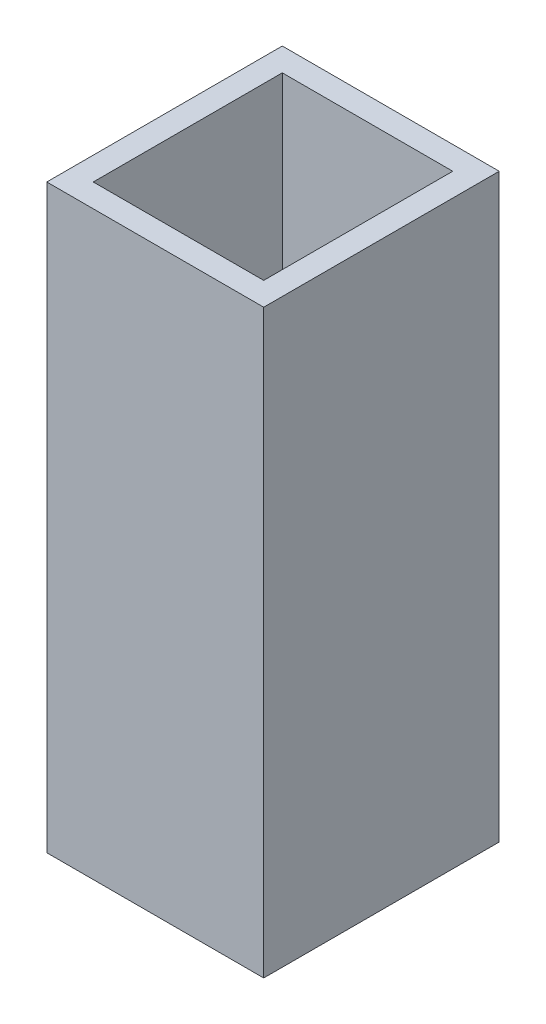
from build123d import *

# Parameters (mm, degrees)
SKETCH1_W                  = 18.67
SKETCH1_H                  = 20.27
EXTRUDE1_DEPTH             = 50
SHELL1_T                   = -2
SKETCH5_W                  = 1
SKETCH5_H                  = 1
EXTRUDE3_DEPTH             = 2
LPATTERN1_COUNT            = 8
LPATTERN1_PITCH            = 2.1429
LPATTERN2_COUNT            = 9
LPATTERN2_PITCH            = 2.125
LPATTERN2_COPY_1_SKETCH_W  = 1
LPATTERN2_COPY_1_SKETCH_H  = 1
LPATTERN2_COPY_1_DEPTH     = 2
LPATTERN2_COPY_2_SKETCH_W  = 1
LPATTERN2_COPY_2_SKETCH_H  = 1
LPATTERN2_COPY_2_DEPTH     = 2
LPATTERN2_COPY_3_SKETCH_W  = 1
LPATTERN2_COPY_3_SKETCH_H  = 1
LPATTERN2_COPY_3_DEPTH     = 2
LPATTERN2_COPY_4_SKETCH_W  = 1
LPATTERN2_COPY_4_SKETCH_H  = 1
LPATTERN2_COPY_4_DEPTH     = 2
LPATTERN2_COPY_5_SKETCH_W  = 1
LPATTERN2_COPY_5_SKETCH_H  = 1
LPATTERN2_COPY_5_DEPTH     = 2
LPATTERN2_COPY_6_SKETCH_W  = 1
LPATTERN2_COPY_6_SKETCH_H  = 1
LPATTERN2_COPY_6_DEPTH     = 2
LPATTERN2_COPY_7_SKETCH_W  = 1
LPATTERN2_COPY_7_SKETCH_H  = 1
LPATTERN2_COPY_7_DEPTH     = 2
LPATTERN2_COPY_8_SKETCH_W  = 1
LPATTERN2_COPY_8_SKETCH_H  = 1
LPATTERN2_COPY_8_DEPTH     = 2
LPATTERN2_COPY_9_SKETCH_W  = 1
LPATTERN2_COPY_9_SKETCH_H  = 1
LPATTERN2_COPY_9_DEPTH     = 2
LPATTERN2_COPY_10_SKETCH_W = 1
LPATTERN2_COPY_10_SKETCH_H = 1
LPATTERN2_COPY_10_DEPTH    = 2
LPATTERN2_COPY_11_SKETCH_W = 1
LPATTERN2_COPY_11_SKETCH_H = 1
LPATTERN2_COPY_11_DEPTH    = 2
LPATTERN2_COPY_12_SKETCH_W = 1
LPATTERN2_COPY_12_SKETCH_H = 1
LPATTERN2_COPY_12_DEPTH    = 2
LPATTERN2_COPY_13_SKETCH_W = 1
LPATTERN2_COPY_13_SKETCH_H = 1
LPATTERN2_COPY_13_DEPTH    = 2
LPATTERN2_COPY_14_SKETCH_W = 1
LPATTERN2_COPY_14_SKETCH_H = 1
LPATTERN2_COPY_14_DEPTH    = 2
LPATTERN2_COPY_15_SKETCH_W = 1
LPATTERN2_COPY_15_SKETCH_H = 1
LPATTERN2_COPY_15_DEPTH    = 2
LPATTERN2_COPY_16_SKETCH_W = 1
LPATTERN2_COPY_16_SKETCH_H = 1
LPATTERN2_COPY_16_DEPTH    = 2
LPATTERN2_COPY_17_SKETCH_W = 1
LPATTERN2_COPY_17_SKETCH_H = 1
LPATTERN2_COPY_17_DEPTH    = 2
LPATTERN2_COPY_18_SKETCH_W = 1
LPATTERN2_COPY_18_SKETCH_H = 1
LPATTERN2_COPY_18_DEPTH    = 2
LPATTERN2_COPY_19_SKETCH_W = 1
LPATTERN2_COPY_19_SKETCH_H = 1
LPATTERN2_COPY_19_DEPTH    = 2
LPATTERN2_COPY_20_SKETCH_W = 1
LPATTERN2_COPY_20_SKETCH_H = 1
LPATTERN2_COPY_20_DEPTH    = 2
LPATTERN2_COPY_21_SKETCH_W = 1
LPATTERN2_COPY_21_SKETCH_H = 1
LPATTERN2_COPY_21_DEPTH    = 2
LPATTERN2_COPY_22_SKETCH_W = 1
LPATTERN2_COPY_22_SKETCH_H = 1
LPATTERN2_COPY_22_DEPTH    = 2
LPATTERN2_COPY_23_SKETCH_W = 1
LPATTERN2_COPY_23_SKETCH_H = 1
LPATTERN2_COPY_23_DEPTH    = 2
LPATTERN2_COPY_24_SKETCH_W = 1
LPATTERN2_COPY_24_SKETCH_H = 1
LPATTERN2_COPY_24_DEPTH    = 2
LPATTERN2_COPY_25_SKETCH_W = 1
LPATTERN2_COPY_25_SKETCH_H = 1
LPATTERN2_COPY_25_DEPTH    = 2
LPATTERN2_COPY_26_SKETCH_W = 1
LPATTERN2_COPY_26_SKETCH_H = 1
LPATTERN2_COPY_26_DEPTH    = 2
LPATTERN2_COPY_27_SKETCH_W = 1
LPATTERN2_COPY_27_SKETCH_H = 1
LPATTERN2_COPY_27_DEPTH    = 2
LPATTERN2_COPY_28_SKETCH_W = 1
LPATTERN2_COPY_28_SKETCH_H = 1
LPATTERN2_COPY_28_DEPTH    = 2
LPATTERN2_COPY_29_SKETCH_W = 1
LPATTERN2_COPY_29_SKETCH_H = 1
LPATTERN2_COPY_29_DEPTH    = 2
LPATTERN2_COPY_30_SKETCH_W = 1
LPATTERN2_COPY_30_SKETCH_H = 1
LPATTERN2_COPY_30_DEPTH    = 2
LPATTERN2_COPY_31_SKETCH_W = 1
LPATTERN2_COPY_31_SKETCH_H = 1
LPATTERN2_COPY_31_DEPTH    = 2
LPATTERN2_COPY_32_SKETCH_W = 1
LPATTERN2_COPY_32_SKETCH_H = 1
LPATTERN2_COPY_32_DEPTH    = 2
LPATTERN2_COPY_33_SKETCH_W = 1
LPATTERN2_COPY_33_SKETCH_H = 1
LPATTERN2_COPY_33_DEPTH    = 2
LPATTERN2_COPY_34_SKETCH_W = 1
LPATTERN2_COPY_34_SKETCH_H = 1
LPATTERN2_COPY_34_DEPTH    = 2
LPATTERN2_COPY_35_SKETCH_W = 1
LPATTERN2_COPY_35_SKETCH_H = 1
LPATTERN2_COPY_35_DEPTH    = 2
LPATTERN2_COPY_36_SKETCH_W = 1
LPATTERN2_COPY_36_SKETCH_H = 1
LPATTERN2_COPY_36_DEPTH    = 2
LPATTERN2_COPY_37_SKETCH_W = 1
LPATTERN2_COPY_37_SKETCH_H = 1
LPATTERN2_COPY_37_DEPTH    = 2
LPATTERN2_COPY_38_SKETCH_W = 1
LPATTERN2_COPY_38_SKETCH_H = 1
LPATTERN2_COPY_38_DEPTH    = 2
LPATTERN2_COPY_39_SKETCH_W = 1
LPATTERN2_COPY_39_SKETCH_H = 1
LPATTERN2_COPY_39_DEPTH    = 2
LPATTERN2_COPY_40_SKETCH_W = 1
LPATTERN2_COPY_40_SKETCH_H = 1
LPATTERN2_COPY_40_DEPTH    = 2
LPATTERN2_COPY_41_SKETCH_W = 1
LPATTERN2_COPY_41_SKETCH_H = 1
LPATTERN2_COPY_41_DEPTH    = 2
LPATTERN2_COPY_42_SKETCH_W = 1
LPATTERN2_COPY_42_SKETCH_H = 1
LPATTERN2_COPY_42_DEPTH    = 2
LPATTERN2_COPY_43_SKETCH_W = 1
LPATTERN2_COPY_43_SKETCH_H = 1
LPATTERN2_COPY_43_DEPTH    = 2
LPATTERN2_COPY_44_SKETCH_W = 1
LPATTERN2_COPY_44_SKETCH_H = 1
LPATTERN2_COPY_44_DEPTH    = 2
LPATTERN2_COPY_45_SKETCH_W = 1
LPATTERN2_COPY_45_SKETCH_H = 1
LPATTERN2_COPY_45_DEPTH    = 2
LPATTERN2_COPY_46_SKETCH_W = 1
LPATTERN2_COPY_46_SKETCH_H = 1
LPATTERN2_COPY_46_DEPTH    = 2
LPATTERN2_COPY_47_SKETCH_W = 1
LPATTERN2_COPY_47_SKETCH_H = 1
LPATTERN2_COPY_47_DEPTH    = 2
LPATTERN2_COPY_48_SKETCH_W = 1
LPATTERN2_COPY_48_SKETCH_H = 1
LPATTERN2_COPY_48_DEPTH    = 2
LPATTERN2_COPY_49_SKETCH_W = 1
LPATTERN2_COPY_49_SKETCH_H = 1
LPATTERN2_COPY_49_DEPTH    = 2
LPATTERN2_COPY_50_SKETCH_W = 1
LPATTERN2_COPY_50_SKETCH_H = 1
LPATTERN2_COPY_50_DEPTH    = 2
LPATTERN2_COPY_51_SKETCH_W = 1
LPATTERN2_COPY_51_SKETCH_H = 1
LPATTERN2_COPY_51_DEPTH    = 2
LPATTERN2_COPY_52_SKETCH_W = 1
LPATTERN2_COPY_52_SKETCH_H = 1
LPATTERN2_COPY_52_DEPTH    = 2
LPATTERN2_COPY_53_SKETCH_W = 1
LPATTERN2_COPY_53_SKETCH_H = 1
LPATTERN2_COPY_53_DEPTH    = 2
LPATTERN2_COPY_54_SKETCH_W = 1
LPATTERN2_COPY_54_SKETCH_H = 1
LPATTERN2_COPY_54_DEPTH    = 2
LPATTERN2_COPY_55_SKETCH_W = 1
LPATTERN2_COPY_55_SKETCH_H = 1
LPATTERN2_COPY_55_DEPTH    = 2
LPATTERN2_COPY_56_SKETCH_W = 1
LPATTERN2_COPY_56_SKETCH_H = 1
LPATTERN2_COPY_56_DEPTH    = 2
SKETCH6_W                  = 16.67
SKETCH6_H                  = 18.27
CUT_EXTRUDE1_DEPTH         = 1.5


with BuildPart() as part:
    # Sketch1 → Extrude1 (new body)
    with BuildSketch(Plane(origin=(0, 0, 0), x_dir=(1, 0, 0), z_dir=(0, 1, 0))):
        Rectangle(SKETCH1_W, SKETCH1_H)
    extrude(amount=EXTRUDE1_DEPTH)

    # Shell1
    shell1_openings = [part.faces().sort_by_distance(p)[0] for p in [
        (0, 50, 0),
    ]]
    offset(amount=SHELL1_T, openings=shell1_openings, kind=Kind.INTERSECTION)

    # Sketch5 → Extrude3 (cut)
    with BuildSketch(Plane.XZ):
        with Locations((-7.5, -8.5)):
            Rectangle(SKETCH5_W, SKETCH5_H)
    extrude3 = extrude(amount=-EXTRUDE3_DEPTH, mode=Mode.SUBTRACT)

    # LPattern1: Extrude3 ×8
    with Locations(*[(i * LPATTERN1_PITCH, 0, 0) for i in range(1, LPATTERN1_COUNT)]):
        add(extrude3, mode=Mode.SUBTRACT)

    # LPattern2: Extrude3 ×9
    with Locations(*[(0, 0, i * LPATTERN2_PITCH) for i in range(1, LPATTERN2_COUNT)]):
        add(extrude3, mode=Mode.SUBTRACT)

    # LPattern2 copy 1 sketch → LPattern2 copy 1 (cut)
    with BuildSketch(Plane(origin=(2.1429, 0, 2.125), x_dir=(1, 0, 0), z_dir=(0, -1, 0))):
        with Locations((-7.5, -8.5)):
            Rectangle(LPATTERN2_COPY_1_SKETCH_W, LPATTERN2_COPY_1_SKETCH_H)
    extrude(amount=-LPATTERN2_COPY_1_DEPTH, mode=Mode.SUBTRACT)

    # LPattern2 copy 2 sketch → LPattern2 copy 2 (cut)
    with BuildSketch(Plane(origin=(2.1429, 0, 4.25), x_dir=(1, 0, 0), z_dir=(0, -1, 0))):
        with Locations((-7.5, -8.5)):
            Rectangle(LPATTERN2_COPY_2_SKETCH_W, LPATTERN2_COPY_2_SKETCH_H)
    extrude(amount=-LPATTERN2_COPY_2_DEPTH, mode=Mode.SUBTRACT)

    # LPattern2 copy 3 sketch → LPattern2 copy 3 (cut)
    with BuildSketch(Plane(origin=(2.1429, 0, 6.375), x_dir=(1, 0, 0), z_dir=(0, -1, 0))):
        with Locations((-7.5, -8.5)):
            Rectangle(LPATTERN2_COPY_3_SKETCH_W, LPATTERN2_COPY_3_SKETCH_H)
    extrude(amount=-LPATTERN2_COPY_3_DEPTH, mode=Mode.SUBTRACT)

    # LPattern2 copy 4 sketch → LPattern2 copy 4 (cut)
    with BuildSketch(Plane(origin=(2.1429, 0, 8.5), x_dir=(1, 0, 0), z_dir=(0, -1, 0))):
        with Locations((-7.5, -8.5)):
            Rectangle(LPATTERN2_COPY_4_SKETCH_W, LPATTERN2_COPY_4_SKETCH_H)
    extrude(amount=-LPATTERN2_COPY_4_DEPTH, mode=Mode.SUBTRACT)

    # LPattern2 copy 5 sketch → LPattern2 copy 5 (cut)
    with BuildSketch(Plane(origin=(2.1429, 0, 10.625), x_dir=(1, 0, 0), z_dir=(0, -1, 0))):
        with Locations((-7.5, -8.5)):
            Rectangle(LPATTERN2_COPY_5_SKETCH_W, LPATTERN2_COPY_5_SKETCH_H)
    extrude(amount=-LPATTERN2_COPY_5_DEPTH, mode=Mode.SUBTRACT)

    # LPattern2 copy 6 sketch → LPattern2 copy 6 (cut)
    with BuildSketch(Plane(origin=(2.1429, 0, 12.75), x_dir=(1, 0, 0), z_dir=(0, -1, 0))):
        with Locations((-7.5, -8.5)):
            Rectangle(LPATTERN2_COPY_6_SKETCH_W, LPATTERN2_COPY_6_SKETCH_H)
    extrude(amount=-LPATTERN2_COPY_6_DEPTH, mode=Mode.SUBTRACT)

    # LPattern2 copy 7 sketch → LPattern2 copy 7 (cut)
    with BuildSketch(Plane(origin=(2.1429, 0, 14.875), x_dir=(1, 0, 0), z_dir=(0, -1, 0))):
        with Locations((-7.5, -8.5)):
            Rectangle(LPATTERN2_COPY_7_SKETCH_W, LPATTERN2_COPY_7_SKETCH_H)
    extrude(amount=-LPATTERN2_COPY_7_DEPTH, mode=Mode.SUBTRACT)

    # LPattern2 copy 8 sketch → LPattern2 copy 8 (cut)
    with BuildSketch(Plane(origin=(2.1429, 0, 17), x_dir=(1, 0, 0), z_dir=(0, -1, 0))):
        with Locations((-7.5, -8.5)):
            Rectangle(LPATTERN2_COPY_8_SKETCH_W, LPATTERN2_COPY_8_SKETCH_H)
    extrude(amount=-LPATTERN2_COPY_8_DEPTH, mode=Mode.SUBTRACT)

    # LPattern2 copy 9 sketch → LPattern2 copy 9 (cut)
    with BuildSketch(Plane(origin=(4.2858, 0, 2.125), x_dir=(1, 0, 0), z_dir=(0, -1, 0))):
        with Locations((-7.5, -8.5)):
            Rectangle(LPATTERN2_COPY_9_SKETCH_W, LPATTERN2_COPY_9_SKETCH_H)
    extrude(amount=-LPATTERN2_COPY_9_DEPTH, mode=Mode.SUBTRACT)

    # LPattern2 copy 10 sketch → LPattern2 copy 10 (cut)
    with BuildSketch(Plane(origin=(4.2858, 0, 4.25), x_dir=(1, 0, 0), z_dir=(0, -1, 0))):
        with Locations((-7.5, -8.5)):
            Rectangle(LPATTERN2_COPY_10_SKETCH_W, LPATTERN2_COPY_10_SKETCH_H)
    extrude(amount=-LPATTERN2_COPY_10_DEPTH, mode=Mode.SUBTRACT)

    # LPattern2 copy 11 sketch → LPattern2 copy 11 (cut)
    with BuildSketch(Plane(origin=(4.2858, 0, 6.375), x_dir=(1, 0, 0), z_dir=(0, -1, 0))):
        with Locations((-7.5, -8.5)):
            Rectangle(LPATTERN2_COPY_11_SKETCH_W, LPATTERN2_COPY_11_SKETCH_H)
    extrude(amount=-LPATTERN2_COPY_11_DEPTH, mode=Mode.SUBTRACT)

    # LPattern2 copy 12 sketch → LPattern2 copy 12 (cut)
    with BuildSketch(Plane(origin=(4.2858, 0, 8.5), x_dir=(1, 0, 0), z_dir=(0, -1, 0))):
        with Locations((-7.5, -8.5)):
            Rectangle(LPATTERN2_COPY_12_SKETCH_W, LPATTERN2_COPY_12_SKETCH_H)
    extrude(amount=-LPATTERN2_COPY_12_DEPTH, mode=Mode.SUBTRACT)

    # LPattern2 copy 13 sketch → LPattern2 copy 13 (cut)
    with BuildSketch(Plane(origin=(4.2858, 0, 10.625), x_dir=(1, 0, 0), z_dir=(0, -1, 0))):
        with Locations((-7.5, -8.5)):
            Rectangle(LPATTERN2_COPY_13_SKETCH_W, LPATTERN2_COPY_13_SKETCH_H)
    extrude(amount=-LPATTERN2_COPY_13_DEPTH, mode=Mode.SUBTRACT)

    # LPattern2 copy 14 sketch → LPattern2 copy 14 (cut)
    with BuildSketch(Plane(origin=(4.2858, 0, 12.75), x_dir=(1, 0, 0), z_dir=(0, -1, 0))):
        with Locations((-7.5, -8.5)):
            Rectangle(LPATTERN2_COPY_14_SKETCH_W, LPATTERN2_COPY_14_SKETCH_H)
    extrude(amount=-LPATTERN2_COPY_14_DEPTH, mode=Mode.SUBTRACT)

    # LPattern2 copy 15 sketch → LPattern2 copy 15 (cut)
    with BuildSketch(Plane(origin=(4.2858, 0, 14.875), x_dir=(1, 0, 0), z_dir=(0, -1, 0))):
        with Locations((-7.5, -8.5)):
            Rectangle(LPATTERN2_COPY_15_SKETCH_W, LPATTERN2_COPY_15_SKETCH_H)
    extrude(amount=-LPATTERN2_COPY_15_DEPTH, mode=Mode.SUBTRACT)

    # LPattern2 copy 16 sketch → LPattern2 copy 16 (cut)
    with BuildSketch(Plane(origin=(4.2858, 0, 17), x_dir=(1, 0, 0), z_dir=(0, -1, 0))):
        with Locations((-7.5, -8.5)):
            Rectangle(LPATTERN2_COPY_16_SKETCH_W, LPATTERN2_COPY_16_SKETCH_H)
    extrude(amount=-LPATTERN2_COPY_16_DEPTH, mode=Mode.SUBTRACT)

    # LPattern2 copy 17 sketch → LPattern2 copy 17 (cut)
    with BuildSketch(Plane(origin=(6.4287, 0, 2.125), x_dir=(1, 0, 0), z_dir=(0, -1, 0))):
        with Locations((-7.5, -8.5)):
            Rectangle(LPATTERN2_COPY_17_SKETCH_W, LPATTERN2_COPY_17_SKETCH_H)
    extrude(amount=-LPATTERN2_COPY_17_DEPTH, mode=Mode.SUBTRACT)

    # LPattern2 copy 18 sketch → LPattern2 copy 18 (cut)
    with BuildSketch(Plane(origin=(6.4287, 0, 4.25), x_dir=(1, 0, 0), z_dir=(0, -1, 0))):
        with Locations((-7.5, -8.5)):
            Rectangle(LPATTERN2_COPY_18_SKETCH_W, LPATTERN2_COPY_18_SKETCH_H)
    extrude(amount=-LPATTERN2_COPY_18_DEPTH, mode=Mode.SUBTRACT)

    # LPattern2 copy 19 sketch → LPattern2 copy 19 (cut)
    with BuildSketch(Plane(origin=(6.4287, 0, 6.375), x_dir=(1, 0, 0), z_dir=(0, -1, 0))):
        with Locations((-7.5, -8.5)):
            Rectangle(LPATTERN2_COPY_19_SKETCH_W, LPATTERN2_COPY_19_SKETCH_H)
    extrude(amount=-LPATTERN2_COPY_19_DEPTH, mode=Mode.SUBTRACT)

    # LPattern2 copy 20 sketch → LPattern2 copy 20 (cut)
    with BuildSketch(Plane(origin=(6.4287, 0, 8.5), x_dir=(1, 0, 0), z_dir=(0, -1, 0))):
        with Locations((-7.5, -8.5)):
            Rectangle(LPATTERN2_COPY_20_SKETCH_W, LPATTERN2_COPY_20_SKETCH_H)
    extrude(amount=-LPATTERN2_COPY_20_DEPTH, mode=Mode.SUBTRACT)

    # LPattern2 copy 21 sketch → LPattern2 copy 21 (cut)
    with BuildSketch(Plane(origin=(6.4287, 0, 10.625), x_dir=(1, 0, 0), z_dir=(0, -1, 0))):
        with Locations((-7.5, -8.5)):
            Rectangle(LPATTERN2_COPY_21_SKETCH_W, LPATTERN2_COPY_21_SKETCH_H)
    extrude(amount=-LPATTERN2_COPY_21_DEPTH, mode=Mode.SUBTRACT)

    # LPattern2 copy 22 sketch → LPattern2 copy 22 (cut)
    with BuildSketch(Plane(origin=(6.4287, 0, 12.75), x_dir=(1, 0, 0), z_dir=(0, -1, 0))):
        with Locations((-7.5, -8.5)):
            Rectangle(LPATTERN2_COPY_22_SKETCH_W, LPATTERN2_COPY_22_SKETCH_H)
    extrude(amount=-LPATTERN2_COPY_22_DEPTH, mode=Mode.SUBTRACT)

    # LPattern2 copy 23 sketch → LPattern2 copy 23 (cut)
    with BuildSketch(Plane(origin=(6.4287, 0, 14.875), x_dir=(1, 0, 0), z_dir=(0, -1, 0))):
        with Locations((-7.5, -8.5)):
            Rectangle(LPATTERN2_COPY_23_SKETCH_W, LPATTERN2_COPY_23_SKETCH_H)
    extrude(amount=-LPATTERN2_COPY_23_DEPTH, mode=Mode.SUBTRACT)

    # LPattern2 copy 24 sketch → LPattern2 copy 24 (cut)
    with BuildSketch(Plane(origin=(6.4287, 0, 17), x_dir=(1, 0, 0), z_dir=(0, -1, 0))):
        with Locations((-7.5, -8.5)):
            Rectangle(LPATTERN2_COPY_24_SKETCH_W, LPATTERN2_COPY_24_SKETCH_H)
    extrude(amount=-LPATTERN2_COPY_24_DEPTH, mode=Mode.SUBTRACT)

    # LPattern2 copy 25 sketch → LPattern2 copy 25 (cut)
    with BuildSketch(Plane(origin=(8.5716, 0, 2.125), x_dir=(1, 0, 0), z_dir=(0, -1, 0))):
        with Locations((-7.5, -8.5)):
            Rectangle(LPATTERN2_COPY_25_SKETCH_W, LPATTERN2_COPY_25_SKETCH_H)
    extrude(amount=-LPATTERN2_COPY_25_DEPTH, mode=Mode.SUBTRACT)

    # LPattern2 copy 26 sketch → LPattern2 copy 26 (cut)
    with BuildSketch(Plane(origin=(8.5716, 0, 4.25), x_dir=(1, 0, 0), z_dir=(0, -1, 0))):
        with Locations((-7.5, -8.5)):
            Rectangle(LPATTERN2_COPY_26_SKETCH_W, LPATTERN2_COPY_26_SKETCH_H)
    extrude(amount=-LPATTERN2_COPY_26_DEPTH, mode=Mode.SUBTRACT)

    # LPattern2 copy 27 sketch → LPattern2 copy 27 (cut)
    with BuildSketch(Plane(origin=(8.5716, 0, 6.375), x_dir=(1, 0, 0), z_dir=(0, -1, 0))):
        with Locations((-7.5, -8.5)):
            Rectangle(LPATTERN2_COPY_27_SKETCH_W, LPATTERN2_COPY_27_SKETCH_H)
    extrude(amount=-LPATTERN2_COPY_27_DEPTH, mode=Mode.SUBTRACT)

    # LPattern2 copy 28 sketch → LPattern2 copy 28 (cut)
    with BuildSketch(Plane(origin=(8.5716, 0, 8.5), x_dir=(1, 0, 0), z_dir=(0, -1, 0))):
        with Locations((-7.5, -8.5)):
            Rectangle(LPATTERN2_COPY_28_SKETCH_W, LPATTERN2_COPY_28_SKETCH_H)
    extrude(amount=-LPATTERN2_COPY_28_DEPTH, mode=Mode.SUBTRACT)

    # LPattern2 copy 29 sketch → LPattern2 copy 29 (cut)
    with BuildSketch(Plane(origin=(8.5716, 0, 10.625), x_dir=(1, 0, 0), z_dir=(0, -1, 0))):
        with Locations((-7.5, -8.5)):
            Rectangle(LPATTERN2_COPY_29_SKETCH_W, LPATTERN2_COPY_29_SKETCH_H)
    extrude(amount=-LPATTERN2_COPY_29_DEPTH, mode=Mode.SUBTRACT)

    # LPattern2 copy 30 sketch → LPattern2 copy 30 (cut)
    with BuildSketch(Plane(origin=(8.5716, 0, 12.75), x_dir=(1, 0, 0), z_dir=(0, -1, 0))):
        with Locations((-7.5, -8.5)):
            Rectangle(LPATTERN2_COPY_30_SKETCH_W, LPATTERN2_COPY_30_SKETCH_H)
    extrude(amount=-LPATTERN2_COPY_30_DEPTH, mode=Mode.SUBTRACT)

    # LPattern2 copy 31 sketch → LPattern2 copy 31 (cut)
    with BuildSketch(Plane(origin=(8.5716, 0, 14.875), x_dir=(1, 0, 0), z_dir=(0, -1, 0))):
        with Locations((-7.5, -8.5)):
            Rectangle(LPATTERN2_COPY_31_SKETCH_W, LPATTERN2_COPY_31_SKETCH_H)
    extrude(amount=-LPATTERN2_COPY_31_DEPTH, mode=Mode.SUBTRACT)

    # LPattern2 copy 32 sketch → LPattern2 copy 32 (cut)
    with BuildSketch(Plane(origin=(8.5716, 0, 17), x_dir=(1, 0, 0), z_dir=(0, -1, 0))):
        with Locations((-7.5, -8.5)):
            Rectangle(LPATTERN2_COPY_32_SKETCH_W, LPATTERN2_COPY_32_SKETCH_H)
    extrude(amount=-LPATTERN2_COPY_32_DEPTH, mode=Mode.SUBTRACT)

    # LPattern2 copy 33 sketch → LPattern2 copy 33 (cut)
    with BuildSketch(Plane(origin=(10.7145, 0, 2.125), x_dir=(1, 0, 0), z_dir=(0, -1, 0))):
        with Locations((-7.5, -8.5)):
            Rectangle(LPATTERN2_COPY_33_SKETCH_W, LPATTERN2_COPY_33_SKETCH_H)
    extrude(amount=-LPATTERN2_COPY_33_DEPTH, mode=Mode.SUBTRACT)

    # LPattern2 copy 34 sketch → LPattern2 copy 34 (cut)
    with BuildSketch(Plane(origin=(10.7145, 0, 4.25), x_dir=(1, 0, 0), z_dir=(0, -1, 0))):
        with Locations((-7.5, -8.5)):
            Rectangle(LPATTERN2_COPY_34_SKETCH_W, LPATTERN2_COPY_34_SKETCH_H)
    extrude(amount=-LPATTERN2_COPY_34_DEPTH, mode=Mode.SUBTRACT)

    # LPattern2 copy 35 sketch → LPattern2 copy 35 (cut)
    with BuildSketch(Plane(origin=(10.7145, 0, 6.375), x_dir=(1, 0, 0), z_dir=(0, -1, 0))):
        with Locations((-7.5, -8.5)):
            Rectangle(LPATTERN2_COPY_35_SKETCH_W, LPATTERN2_COPY_35_SKETCH_H)
    extrude(amount=-LPATTERN2_COPY_35_DEPTH, mode=Mode.SUBTRACT)

    # LPattern2 copy 36 sketch → LPattern2 copy 36 (cut)
    with BuildSketch(Plane(origin=(10.7145, 0, 8.5), x_dir=(1, 0, 0), z_dir=(0, -1, 0))):
        with Locations((-7.5, -8.5)):
            Rectangle(LPATTERN2_COPY_36_SKETCH_W, LPATTERN2_COPY_36_SKETCH_H)
    extrude(amount=-LPATTERN2_COPY_36_DEPTH, mode=Mode.SUBTRACT)

    # LPattern2 copy 37 sketch → LPattern2 copy 37 (cut)
    with BuildSketch(Plane(origin=(10.7145, 0, 10.625), x_dir=(1, 0, 0), z_dir=(0, -1, 0))):
        with Locations((-7.5, -8.5)):
            Rectangle(LPATTERN2_COPY_37_SKETCH_W, LPATTERN2_COPY_37_SKETCH_H)
    extrude(amount=-LPATTERN2_COPY_37_DEPTH, mode=Mode.SUBTRACT)

    # LPattern2 copy 38 sketch → LPattern2 copy 38 (cut)
    with BuildSketch(Plane(origin=(10.7145, 0, 12.75), x_dir=(1, 0, 0), z_dir=(0, -1, 0))):
        with Locations((-7.5, -8.5)):
            Rectangle(LPATTERN2_COPY_38_SKETCH_W, LPATTERN2_COPY_38_SKETCH_H)
    extrude(amount=-LPATTERN2_COPY_38_DEPTH, mode=Mode.SUBTRACT)

    # LPattern2 copy 39 sketch → LPattern2 copy 39 (cut)
    with BuildSketch(Plane(origin=(10.7145, 0, 14.875), x_dir=(1, 0, 0), z_dir=(0, -1, 0))):
        with Locations((-7.5, -8.5)):
            Rectangle(LPATTERN2_COPY_39_SKETCH_W, LPATTERN2_COPY_39_SKETCH_H)
    extrude(amount=-LPATTERN2_COPY_39_DEPTH, mode=Mode.SUBTRACT)

    # LPattern2 copy 40 sketch → LPattern2 copy 40 (cut)
    with BuildSketch(Plane(origin=(10.7145, 0, 17), x_dir=(1, 0, 0), z_dir=(0, -1, 0))):
        with Locations((-7.5, -8.5)):
            Rectangle(LPATTERN2_COPY_40_SKETCH_W, LPATTERN2_COPY_40_SKETCH_H)
    extrude(amount=-LPATTERN2_COPY_40_DEPTH, mode=Mode.SUBTRACT)

    # LPattern2 copy 41 sketch → LPattern2 copy 41 (cut)
    with BuildSketch(Plane(origin=(12.8574, 0, 2.125), x_dir=(1, 0, 0), z_dir=(0, -1, 0))):
        with Locations((-7.5, -8.5)):
            Rectangle(LPATTERN2_COPY_41_SKETCH_W, LPATTERN2_COPY_41_SKETCH_H)
    extrude(amount=-LPATTERN2_COPY_41_DEPTH, mode=Mode.SUBTRACT)

    # LPattern2 copy 42 sketch → LPattern2 copy 42 (cut)
    with BuildSketch(Plane(origin=(12.8574, 0, 4.25), x_dir=(1, 0, 0), z_dir=(0, -1, 0))):
        with Locations((-7.5, -8.5)):
            Rectangle(LPATTERN2_COPY_42_SKETCH_W, LPATTERN2_COPY_42_SKETCH_H)
    extrude(amount=-LPATTERN2_COPY_42_DEPTH, mode=Mode.SUBTRACT)

    # LPattern2 copy 43 sketch → LPattern2 copy 43 (cut)
    with BuildSketch(Plane(origin=(12.8574, 0, 6.375), x_dir=(1, 0, 0), z_dir=(0, -1, 0))):
        with Locations((-7.5, -8.5)):
            Rectangle(LPATTERN2_COPY_43_SKETCH_W, LPATTERN2_COPY_43_SKETCH_H)
    extrude(amount=-LPATTERN2_COPY_43_DEPTH, mode=Mode.SUBTRACT)

    # LPattern2 copy 44 sketch → LPattern2 copy 44 (cut)
    with BuildSketch(Plane(origin=(12.8574, 0, 8.5), x_dir=(1, 0, 0), z_dir=(0, -1, 0))):
        with Locations((-7.5, -8.5)):
            Rectangle(LPATTERN2_COPY_44_SKETCH_W, LPATTERN2_COPY_44_SKETCH_H)
    extrude(amount=-LPATTERN2_COPY_44_DEPTH, mode=Mode.SUBTRACT)

    # LPattern2 copy 45 sketch → LPattern2 copy 45 (cut)
    with BuildSketch(Plane(origin=(12.8574, 0, 10.625), x_dir=(1, 0, 0), z_dir=(0, -1, 0))):
        with Locations((-7.5, -8.5)):
            Rectangle(LPATTERN2_COPY_45_SKETCH_W, LPATTERN2_COPY_45_SKETCH_H)
    extrude(amount=-LPATTERN2_COPY_45_DEPTH, mode=Mode.SUBTRACT)

    # LPattern2 copy 46 sketch → LPattern2 copy 46 (cut)
    with BuildSketch(Plane(origin=(12.8574, 0, 12.75), x_dir=(1, 0, 0), z_dir=(0, -1, 0))):
        with Locations((-7.5, -8.5)):
            Rectangle(LPATTERN2_COPY_46_SKETCH_W, LPATTERN2_COPY_46_SKETCH_H)
    extrude(amount=-LPATTERN2_COPY_46_DEPTH, mode=Mode.SUBTRACT)

    # LPattern2 copy 47 sketch → LPattern2 copy 47 (cut)
    with BuildSketch(Plane(origin=(12.8574, 0, 14.875), x_dir=(1, 0, 0), z_dir=(0, -1, 0))):
        with Locations((-7.5, -8.5)):
            Rectangle(LPATTERN2_COPY_47_SKETCH_W, LPATTERN2_COPY_47_SKETCH_H)
    extrude(amount=-LPATTERN2_COPY_47_DEPTH, mode=Mode.SUBTRACT)

    # LPattern2 copy 48 sketch → LPattern2 copy 48 (cut)
    with BuildSketch(Plane(origin=(12.8574, 0, 17), x_dir=(1, 0, 0), z_dir=(0, -1, 0))):
        with Locations((-7.5, -8.5)):
            Rectangle(LPATTERN2_COPY_48_SKETCH_W, LPATTERN2_COPY_48_SKETCH_H)
    extrude(amount=-LPATTERN2_COPY_48_DEPTH, mode=Mode.SUBTRACT)

    # LPattern2 copy 49 sketch → LPattern2 copy 49 (cut)
    with BuildSketch(Plane(origin=(15.0003, 0, 2.125), x_dir=(1, 0, 0), z_dir=(0, -1, 0))):
        with Locations((-7.5, -8.5)):
            Rectangle(LPATTERN2_COPY_49_SKETCH_W, LPATTERN2_COPY_49_SKETCH_H)
    extrude(amount=-LPATTERN2_COPY_49_DEPTH, mode=Mode.SUBTRACT)

    # LPattern2 copy 50 sketch → LPattern2 copy 50 (cut)
    with BuildSketch(Plane(origin=(15.0003, 0, 4.25), x_dir=(1, 0, 0), z_dir=(0, -1, 0))):
        with Locations((-7.5, -8.5)):
            Rectangle(LPATTERN2_COPY_50_SKETCH_W, LPATTERN2_COPY_50_SKETCH_H)
    extrude(amount=-LPATTERN2_COPY_50_DEPTH, mode=Mode.SUBTRACT)

    # LPattern2 copy 51 sketch → LPattern2 copy 51 (cut)
    with BuildSketch(Plane(origin=(15.0003, 0, 6.375), x_dir=(1, 0, 0), z_dir=(0, -1, 0))):
        with Locations((-7.5, -8.5)):
            Rectangle(LPATTERN2_COPY_51_SKETCH_W, LPATTERN2_COPY_51_SKETCH_H)
    extrude(amount=-LPATTERN2_COPY_51_DEPTH, mode=Mode.SUBTRACT)

    # LPattern2 copy 52 sketch → LPattern2 copy 52 (cut)
    with BuildSketch(Plane(origin=(15.0003, 0, 8.5), x_dir=(1, 0, 0), z_dir=(0, -1, 0))):
        with Locations((-7.5, -8.5)):
            Rectangle(LPATTERN2_COPY_52_SKETCH_W, LPATTERN2_COPY_52_SKETCH_H)
    extrude(amount=-LPATTERN2_COPY_52_DEPTH, mode=Mode.SUBTRACT)

    # LPattern2 copy 53 sketch → LPattern2 copy 53 (cut)
    with BuildSketch(Plane(origin=(15.0003, 0, 10.625), x_dir=(1, 0, 0), z_dir=(0, -1, 0))):
        with Locations((-7.5, -8.5)):
            Rectangle(LPATTERN2_COPY_53_SKETCH_W, LPATTERN2_COPY_53_SKETCH_H)
    extrude(amount=-LPATTERN2_COPY_53_DEPTH, mode=Mode.SUBTRACT)

    # LPattern2 copy 54 sketch → LPattern2 copy 54 (cut)
    with BuildSketch(Plane(origin=(15.0003, 0, 12.75), x_dir=(1, 0, 0), z_dir=(0, -1, 0))):
        with Locations((-7.5, -8.5)):
            Rectangle(LPATTERN2_COPY_54_SKETCH_W, LPATTERN2_COPY_54_SKETCH_H)
    extrude(amount=-LPATTERN2_COPY_54_DEPTH, mode=Mode.SUBTRACT)

    # LPattern2 copy 55 sketch → LPattern2 copy 55 (cut)
    with BuildSketch(Plane(origin=(15.0003, 0, 14.875), x_dir=(1, 0, 0), z_dir=(0, -1, 0))):
        with Locations((-7.5, -8.5)):
            Rectangle(LPATTERN2_COPY_55_SKETCH_W, LPATTERN2_COPY_55_SKETCH_H)
    extrude(amount=-LPATTERN2_COPY_55_DEPTH, mode=Mode.SUBTRACT)

    # LPattern2 copy 56 sketch → LPattern2 copy 56 (cut)
    with BuildSketch(Plane(origin=(15.0003, 0, 17), x_dir=(1, 0, 0), z_dir=(0, -1, 0))):
        with Locations((-7.5, -8.5)):
            Rectangle(LPATTERN2_COPY_56_SKETCH_W, LPATTERN2_COPY_56_SKETCH_H)
    extrude(amount=-LPATTERN2_COPY_56_DEPTH, mode=Mode.SUBTRACT)

    # Sketch6 → Cut-Extrude1 (cut)
    with BuildSketch(Plane(origin=(0, 2, 0), x_dir=(1, 0, 0), z_dir=(0, 1, 0))):
        Rectangle(SKETCH6_W, SKETCH6_H)
    extrude(amount=CUT_EXTRUDE1_DEPTH, mode=Mode.SUBTRACT)


solid = part.part
